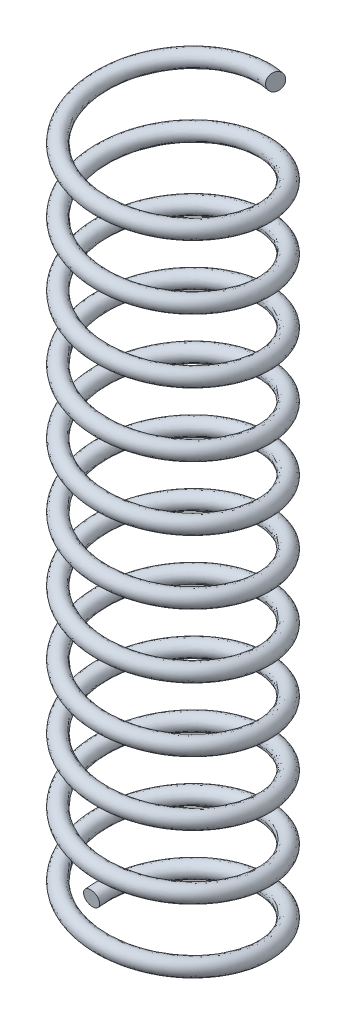
from build123d import *

# Parameters (mm, degrees)
SWEEP1_PITCH       = 2
SWEEP1_HEIGHT      = 22.6
SWEEP1_RADIUS      = 2.55
SWEEP1_START_ANGLE = -90
SWEEP1_PROFILE_R   = 0.25


with BuildPart() as part:
    # Sweep1: sweep along a helix
    with BuildLine() as sweep1_path:
        add(Helix(SWEEP1_PITCH, SWEEP1_HEIGHT, SWEEP1_RADIUS, center=(0, 0, 0), direction=(0, 1, 0), lefthand=True, mode=Mode.PRIVATE).rotate(Axis((0, 0, 0), (0, 1, 0)), SWEEP1_START_ANGLE))
    # Sweep1 profile (on start of the path) → Sweep1 (sweep)
    with BuildSketch(Plane(origin=(-2.55, 0, 0), x_dir=(0, -0.992298941, -0.123866103), z_dir=(0, 0.123866103, -0.992298941))):
        Circle(SWEEP1_PROFILE_R)
    sweep(path=sweep1_path.line, is_frenet=True)


solid = part.part
